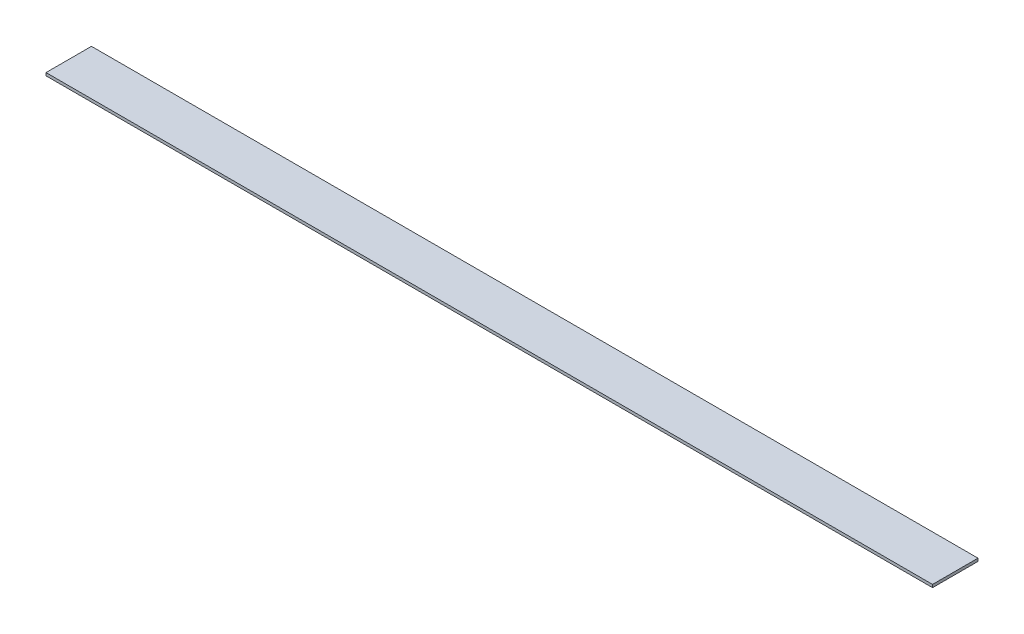
from build123d import *

# Parameters (mm, degrees)
SKETCH1_W           = 990.6
SKETCH1_H           = 50.8
BOSS_EXTRUDE1_DEPTH = 3.175


with BuildPart() as part:
    # Sketch1 → Boss-Extrude1 (new body)
    with BuildSketch(Plane(origin=(0, 0, 0), x_dir=(1, 0, 0), z_dir=(0, 1, 0))):
        Rectangle(SKETCH1_W, SKETCH1_H)
    extrude(amount=BOSS_EXTRUDE1_DEPTH)


solid = part.part
